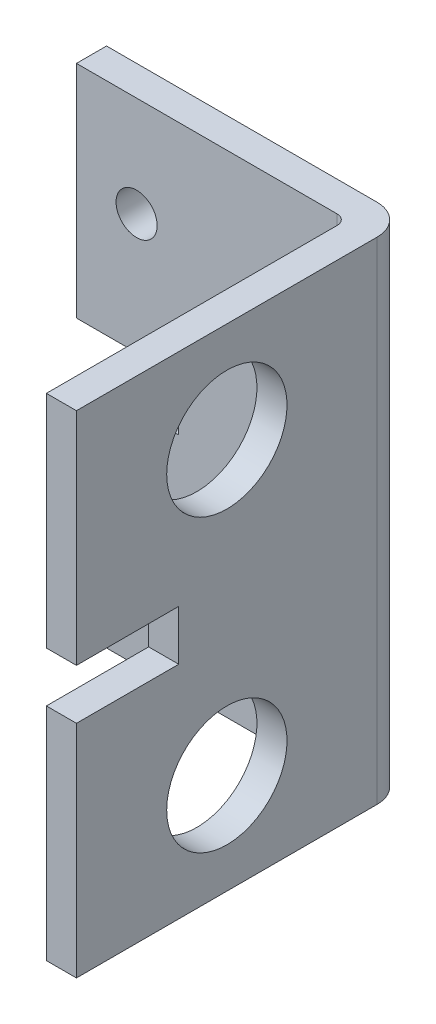
from build123d import *

# Parameters (mm, degrees)
SKETCH2_W               = 27
SKETCH2_H               = 49
SKETCH2_R               = 2.05
BOSS_EXTRUDE1_DEPTH     = 3
BOSS_EXTRUDE2_DEPTH     = 49
SKETCH5_R               = 6
CUT_EXTRUDE1_DEPTH      = 4
FILLET1_R               = 1
SKETCH6_W               = 13.2
SKETCH6_H               = 5
CUT_EXTRUDE2_DEPTH      = 4
SKETCH7_W               = 10.2
SKETCH7_H               = 5
CUT_EXTRUDE3_DEPTH      = 28
CUT_EXTRUDE3_DEPTH_BACK = 4


with BuildPart() as part:
    # Sketch2 → Boss-Extrude1 (new body)
    with BuildSketch(Plane.XY):
        with Locations((13.5, 24.5)):
            Rectangle(SKETCH2_W, SKETCH2_H)
        with Locations((6, 39)):
            Circle(SKETCH2_R, mode=Mode.SUBTRACT)
        with Locations((21, 39)):
            Circle(SKETCH2_R, mode=Mode.SUBTRACT)
        with Locations((6, 10)):
            Circle(SKETCH2_R, mode=Mode.SUBTRACT)
        with Locations((21, 10)):
            Circle(SKETCH2_R, mode=Mode.SUBTRACT)
    extrude(amount=BOSS_EXTRUDE1_DEPTH)

    # Sketch4 → Boss-Extrude2 (add)
    with BuildSketch(Plane(origin=(0, 49, 0), x_dir=(1, 0, 0), z_dir=(0, 1, 0))):
        with BuildLine():
            Line((30, -3), (30, -33))
            Line((30, -33), (27, -33))
            Line((27, -33), (27, 0))
            ThreePointArc((27, 0), (29.121320344, -0.878679656), (30, -3))
        make_face()
    extrude(amount=-BOSS_EXTRUDE2_DEPTH)

    # Sketch5 → Cut-Extrude1 (cut, through all)
    with BuildSketch(Plane.ZY.offset(-27)):
        with Locations((18, 39)):
            Circle(SKETCH5_R)
        with Locations((18, 10)):
            Circle(SKETCH5_R)
    extrude(amount=-CUT_EXTRUDE1_DEPTH, mode=Mode.SUBTRACT)

    # Fillet1
    fillet1_edges = [part.edges().sort_by_distance(p)[0] for p in [
        (27, 24.5, 3),
    ]]
    fillet(fillet1_edges, radius=FILLET1_R)

    # Sketch6 → Cut-Extrude2 (cut, through all)
    with BuildSketch(Plane.XY.offset(3)):
        with Locations((3.6, 24.5)):
            Rectangle(SKETCH6_W, SKETCH6_H)
    extrude(amount=-CUT_EXTRUDE2_DEPTH, mode=Mode.SUBTRACT)

    # Sketch7 → Cut-Extrude3 (cut, two sides)
    with BuildSketch(Plane.ZY.offset(-27)) as cut_extrude3_sk:
        with Locations((27.9, 24.5)):
            Rectangle(SKETCH7_W, SKETCH7_H)
    extrude(amount=CUT_EXTRUDE3_DEPTH, mode=Mode.SUBTRACT)
    extrude(cut_extrude3_sk.sketch, amount=-CUT_EXTRUDE3_DEPTH_BACK, mode=Mode.SUBTRACT)


solid = part.part
